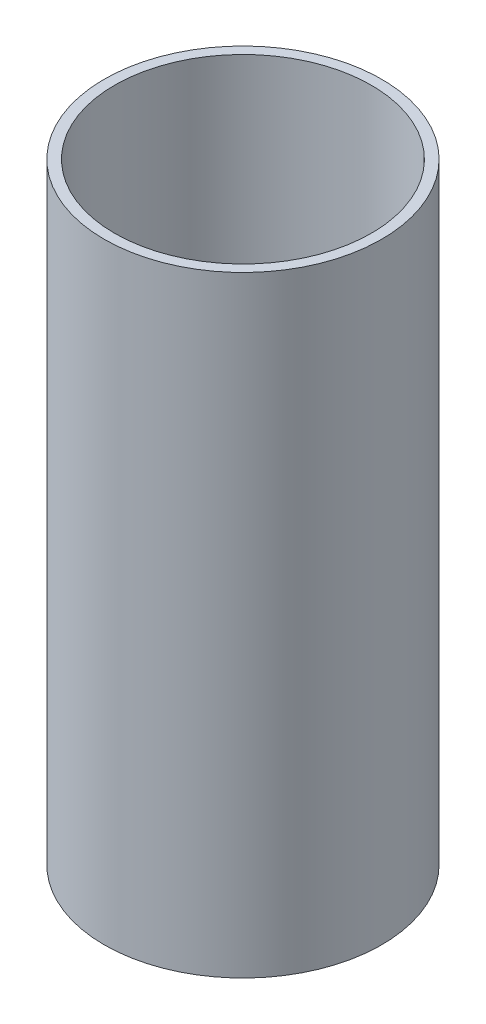
from build123d import *

# Parameters (mm, degrees)
SKETCH1_R      = 109.5375
SKETCH1_R_2    = 101.3587
EXTRUDE1_DEPTH = 241.3


with BuildPart() as part:
    # Sketch1 → Extrude1 (new body, symmetric)
    with BuildSketch(Plane(origin=(0, 0, 0), x_dir=(1, 0, 0), z_dir=(0, 1, 0))):
        Circle(SKETCH1_R)
        Circle(SKETCH1_R_2, mode=Mode.SUBTRACT)
    extrude(amount=EXTRUDE1_DEPTH, both=True)


solid = part.part
